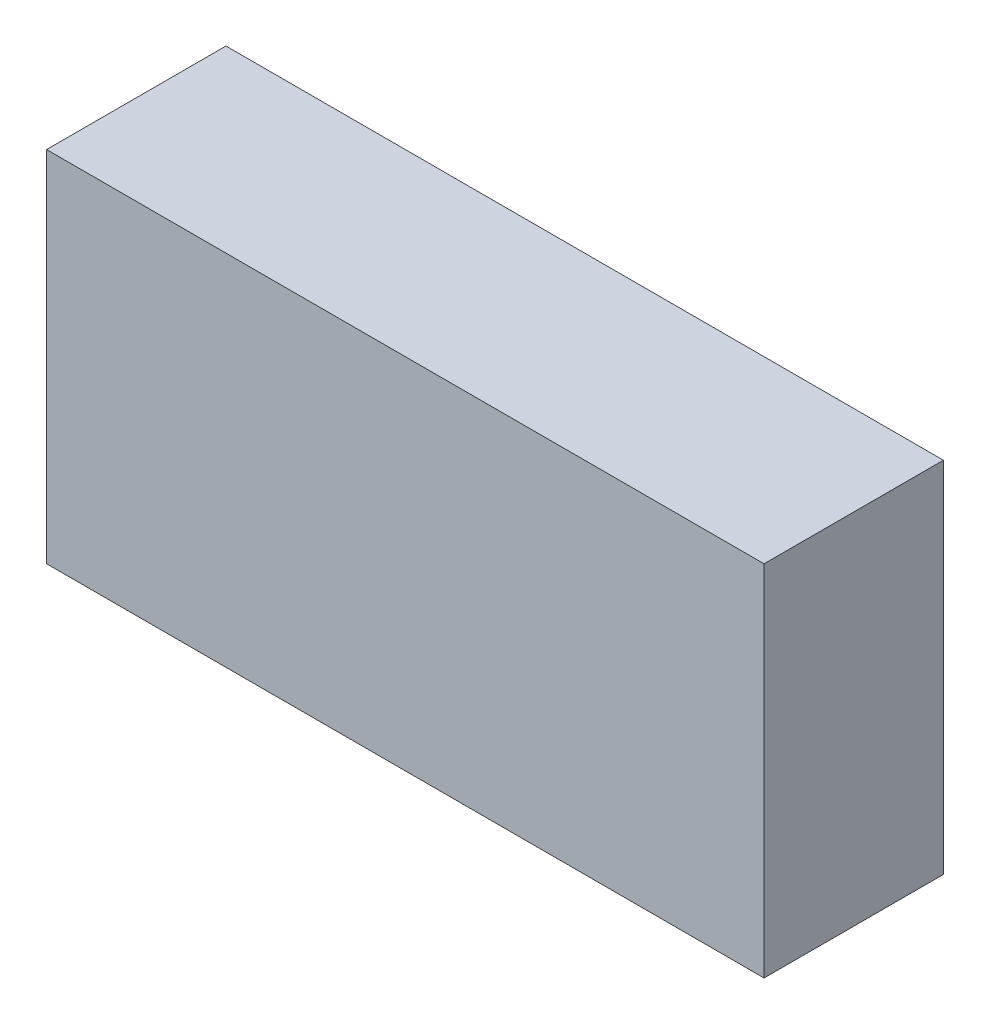
from build123d import *

# Parameters (mm, degrees)
SZKIC1_W                    = 20
SZKIC1_H                    = 10
DODANIE_WYCI_GNI_CIE1_DEPTH = 5


with BuildPart() as part:
    # Szkic1 → Dodanie-wyciągnięcie1 (new body)
    with BuildSketch(Plane.XY):
        with Locations((10, 5)):
            Rectangle(SZKIC1_W, SZKIC1_H)
    extrude(amount=DODANIE_WYCI_GNI_CIE1_DEPTH)


solid = part.part
